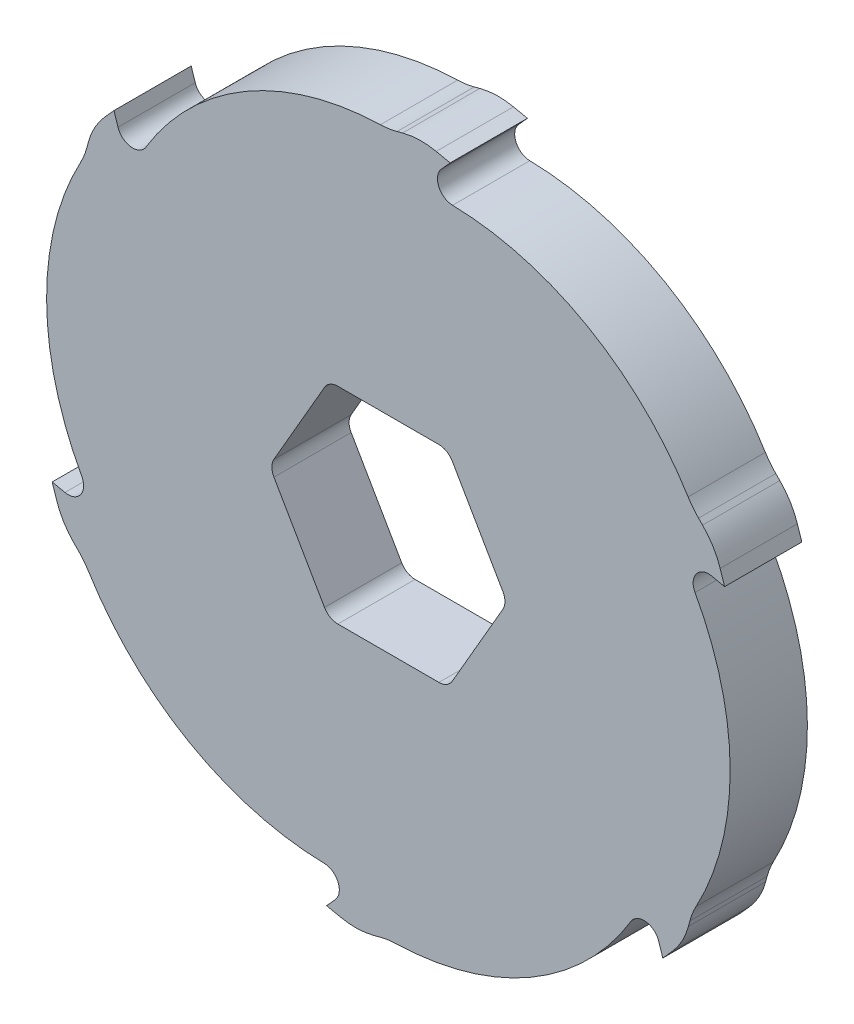
from build123d import *

# Parameters (mm, degrees)
SKETCH1_R           = 70
BOSS_EXTRUDE1_DEPTH = 7.5
CUT_EXTRUDE1_DEPTH  = 15
FILLET1_R           = 14
FILLET2_R           = 3


with BuildPart() as part:
    # Sketch1 → Boss-Extrude1 (new body, symmetric)
    with BuildSketch(Plane.XY):
        Circle(SKETCH1_R)
        with BuildLine():
            Line((22.227985364, 1.5), (12.413030788, 18.5))
            ThreePointArc((12.413030788, 18.5), (11.314954576, 19.598076211), (9.814954576, 20))
            Line((9.814954576, 20), (-9.814954576, 20))
            ThreePointArc((-9.814954576, 20), (-11.314954576, 19.598076211), (-12.413030788, 18.5))
            Line((-12.413030788, 18.5), (-22.227985364, 1.5))
            ThreePointArc((-22.227985364, 1.5), (-22.629909152, 0), (-22.227985364, -1.5))
            Line((-22.227985364, -1.5), (-12.413030788, -18.5))
            ThreePointArc((-12.413030788, -18.5), (-11.314954576, -19.598076211), (-9.814954576, -20))
            Line((-9.814954576, -20), (9.814954576, -20))
            ThreePointArc((9.814954576, -20), (11.314954576, -19.598076211), (12.413030788, -18.5))
            Line((12.413030788, -18.5), (22.227985364, -1.5))
            ThreePointArc((22.227985364, -1.5), (22.629909152, 0), (22.227985364, 1.5))
        make_face(mode=Mode.SUBTRACT)
    extrude(amount=BOSS_EXTRUDE1_DEPTH, both=True)

    # Sketch2 → Cut-Extrude1 (cut)
    with BuildSketch(Plane.XY.offset(7.5)):
        with BuildLine():
            ThreePointArc((63.398675482, 29.675039126), (40.067343971, 57.398675482), (6, 69.742383097))
            Line((6, 69.742383097), (12, 68.467043727))
            Line((12, 68.467043727), (5.525264217, 61.276121136))
            ThreePointArc((5.525264217, 61.276121136), (36.300148732, 55.601545074), (59.006370637, 34.067343971))
            Line((59.006370637, 34.067343971), (63.398675482, 29.675039126))
        make_face()
        with BuildLine():
            ThreePointArc((-50.304045441, 35.423079743), (-30.002276158, 59.2376235), (0, 68.134687942))
            Line((0, 68.134687942), (6, 69.742383097))
            ThreePointArc((6, 69.742383097), (-29.675039126, 63.398675482), (-57.398675482, 40.067343971))
            Line((-57.398675482, 40.067343971), (-53.294199189, 44.625826709))
            Line((-53.294199189, 44.625826709), (-50.304045441, 35.423079743))
        make_face()
        with BuildLine():
            Line((-59.006370637, 34.067343971), (-57.398675482, 40.067343971))
            ThreePointArc((-57.398675482, 40.067343971), (-69.742383097, 6), (-63.398675482, -29.675039126))
            Line((-63.398675482, -29.675039126), (-65.294199189, -23.841217018))
            Line((-65.294199189, -23.841217018), (-55.829309658, -25.853041393))
            ThreePointArc((-55.829309658, -25.853041393), (-66.30242489, 3.636078426), (-59.006370637, 34.067343971))
        make_face()
        with BuildLine():
            Line((-59.006370637, -34.067343971), (-63.398675482, -29.675039126))
            ThreePointArc((-63.398675482, -29.675039126), (-40.067343971, -57.398675482), (-6, -69.742383097))
            Line((-6, -69.742383097), (-12, -68.467043727))
            Line((-12, -68.467043727), (-5.525264217, -61.276121136))
            ThreePointArc((-5.525264217, -61.276121136), (-36.300148732, -55.601545074), (-59.006370637, -34.067343971))
        make_face()
        with BuildLine():
            ThreePointArc((-6, -69.742383097), (29.675039126, -63.398675482), (57.398675482, -40.067343971))
            Line((57.398675482, -40.067343971), (53.294199189, -44.625826709))
            Line((53.294199189, -44.625826709), (50.304045441, -35.423079743))
            ThreePointArc((50.304045441, -35.423079743), (30.002276158, -59.2376235), (0, -68.134687942))
            Line((0, -68.134687942), (-6, -69.742383097))
        make_face()
        with BuildLine():
            ThreePointArc((70, 0), (68.329742001, 15.200209147), (63.398675482, 29.675039126))
            Line((63.398675482, 29.675039126), (65.294199189, 23.841217018))
            Line((65.294199189, 23.841217018), (55.829309658, 25.853041393))
            ThreePointArc((55.829309658, 25.853041393), (66.30242489, -3.636078426), (59.006370637, -34.067343971))
            Line((59.006370637, -34.067343971), (57.398675482, -40.067343971))
            ThreePointArc((57.398675482, -40.067343971), (66.77539698, -21.001103736), (70, 0))
        make_face()
    extrude(amount=-CUT_EXTRUDE1_DEPTH, mode=Mode.SUBTRACT)

    # Fillet1
    fillet1_edges = [part.edges().sort_by_distance(p)[0] for p in [
        (-59.006370637, -34.067343971, 0),
        (-6, -69.742383097, 0),
        (59.006370637, -34.067343971, 0),
        (59.006370637, 34.067343971, 0),
        (6, 69.742383097, 0),
        (63.398675482, 29.675039126, 0),
        (-59.006370637, 34.067343971, 0),
        (-63.398675482, -29.675039126, 0),
        (0, -68.134687942, 0),
        (57.398675482, -40.067343971, 0),
        (0, 68.134687942, 0),
        (-57.398675482, 40.067343971, 0),
    ]]
    fillet(fillet1_edges, radius=FILLET1_R)

    # Fillet2
    fillet2_edges = [part.edges().sort_by_distance(p)[0] for p in [
        (-5.525264217, -61.276121136, 0),
        (55.829309658, 25.853041393, 0),
        (5.525264217, 61.276121136, 0),
        (-55.829309658, -25.853041393, 0),
        (50.304045441, -35.423079743, 0),
        (-50.304045441, 35.423079743, 0),
    ]]
    fillet(fillet2_edges, radius=FILLET2_R)


solid = part.part
